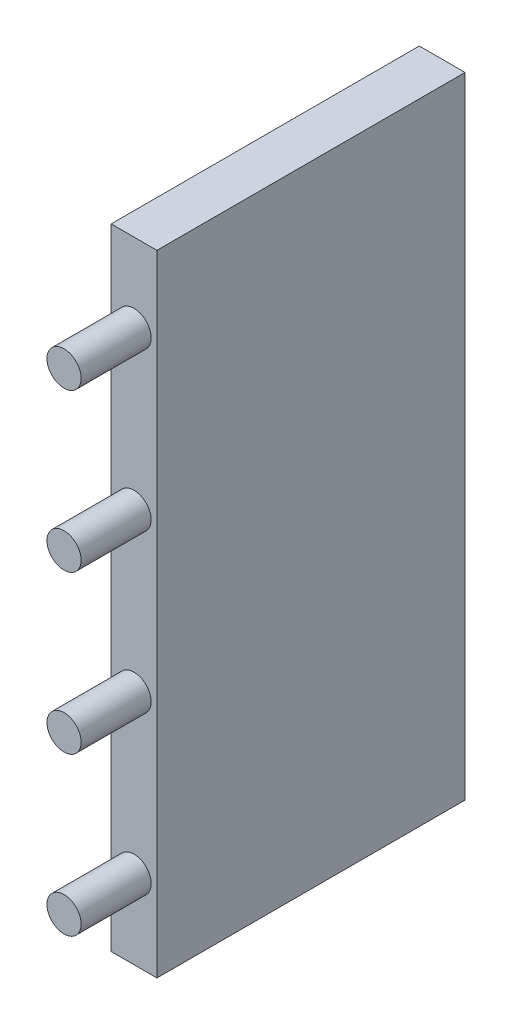
from build123d import *

# Parameters (mm, degrees)
SKETCH1_W           = 55.88
SKETCH1_H           = 114.3
BOSS_EXTRUDE1_DEPTH = 8.3
SKETCH2_R           = 3.1
BOSS_EXTRUDE2_DEPTH = 12.7
LPATTERN1_COUNT     = 4
LPATTERN1_PITCH     = 28.575


with BuildPart() as part:
    # Sketch1 → Boss-Extrude1 (new body)
    with BuildSketch(Plane(origin=(0, 0, 0), x_dir=(0, 0, -1), z_dir=(1, 0, 0))):
        Rectangle(SKETCH1_W, SKETCH1_H)
    extrude(amount=BOSS_EXTRUDE1_DEPTH)

    # Sketch2 → Boss-Extrude2 (add)
    with BuildSketch(Plane.XY.offset(27.94)):
        with Locations(Location((4.15, -42.8625, 0), (0, 0, 90))):  # turned: the seam where the file's is
            Circle(SKETCH2_R)
    boss_extrude2 = extrude(amount=BOSS_EXTRUDE2_DEPTH)

    # LPattern1: Boss-Extrude2 ×4
    with Locations(*[(0, i * LPATTERN1_PITCH, 0) for i in range(1, LPATTERN1_COUNT)]):
        add(boss_extrude2)


solid = part.part
